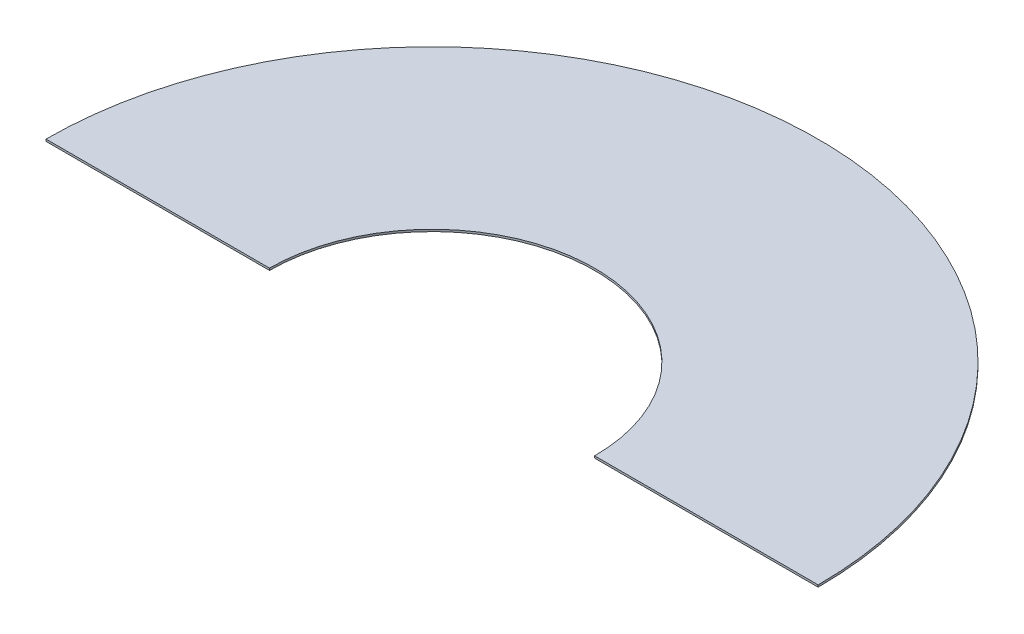
from build123d import *

# Parameters (mm, degrees)
BOSS_EXTRUDE1_DEPTH = 2


with BuildPart() as part:
    # Sketch1 → Boss-Extrude1 (new body)
    with BuildSketch(Plane(origin=(0, 0, 0), x_dir=(1, 0, 0), z_dir=(0, 1, 0))):
        with BuildLine():
            Line((-380, 0), (-160, 0))
            ThreePointArc((-160, 0), (0, 160), (160, 0))
            Line((160, 0), (380, 0))
            ThreePointArc((380, 0), (0, 380), (-380, 0))
        make_face()
    extrude(amount=BOSS_EXTRUDE1_DEPTH)


solid = part.part
